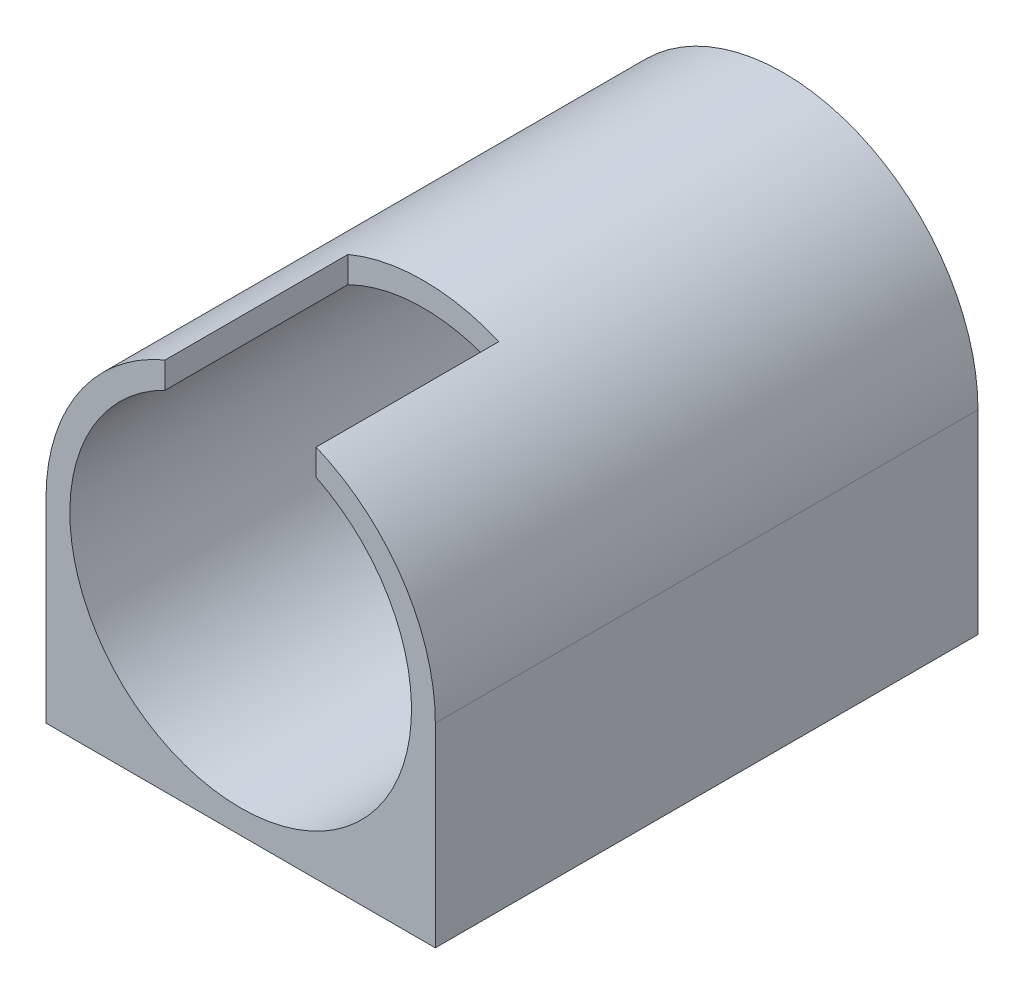
from build123d import *

# Parameters (mm, degrees)
ESQUISSE1_R             = 24.5
ESQUISSE1_R_2           = 21.5
BOSS_EXTRU_1_DEPTH      = 65.3
ESQUISSE2_R             = 21.5
ESQUISSE2_R_2           = 14.5
BOSS_EXTRU_2_DEPTH      = 3
ESQUISSE3_R             = 1.65
ENL_V_MAT_EXTRU_1_DEPTH = 3
ESQUISSE4_W             = 19
ESQUISSE4_H             = 5.738367338
ENL_V_MAT_EXTRU_2_DEPTH = 23
ESQUISSE5_W             = 68.3
ESQUISSE5_H             = 3
BOSS_EXTRU_3_DEPTH      = 17
ESQUISSE6_W             = 68.3
ESQUISSE6_H             = 3
BOSS_EXTRU_4_DEPTH      = 17
ESQUISSE7_R             = 2
ENL_V_MAT_EXTRU_3_DEPTH = 10
ESQUISSE9_R             = 2
ENL_V_MAT_EXTRU_4_DEPTH = 10
ESQUISSE10_R            = 3.5
ENL_V_MAT_EXTRU_5_DEPTH = 1
ESQUISSE11_R            = 2.75
ENL_V_MAT_EXTRU_6_DEPTH = 8
ESQUISSE12_W            = 17
ESQUISSE12_H            = 3
ENL_V_MAT_EXTRU_7_DEPTH = 74


with BuildPart() as part:
    # Esquisse1 → Boss.-Extru.1 (new body)
    with BuildSketch(Plane.XY):
        Circle(ESQUISSE1_R)
        Circle(ESQUISSE1_R_2, mode=Mode.SUBTRACT)
        with BuildLine():
            Line((-24.5, 0), (-24.5, -24.5))
            Line((-24.5, -24.5), (-6e-09, -24.5))
            ThreePointArc((-6e-09, -24.5), (-17.324116141, -17.324116137), (-24.5, 0))
        make_face()
        with BuildLine():
            ThreePointArc((24.5, 0), (17.324116137, -17.324116141), (-6e-09, -24.5))
            Line((-6e-09, -24.5), (24.5, -24.5))
            Line((24.5, -24.5), (24.5, 0))
        make_face()
    extrude(amount=BOSS_EXTRU_1_DEPTH)

    # Esquisse2 → Boss.-Extru.2 (add)
    with BuildSketch(Plane(origin=(0, 0, 0), x_dir=(-1, 0, 0), z_dir=(0, 0, -1))):
        with BuildLine():
            ThreePointArc((24.5, 0), (0, 24.5), (-24.5, 0))
            ThreePointArc((-24.5, 0), (-17.324116141, -17.324116137), (-6e-09, -24.5))
            ThreePointArc((-6e-09, -24.5), (17.324116137, -17.324116141), (24.5, 0))
        make_face()
        with Locations(Location((0, 0, 0), (0, 0, 180))):
            Circle(ESQUISSE2_R, mode=Mode.SUBTRACT)
        with Locations(Location((0, 0, 0), (0, 0, 180))):
            Circle(ESQUISSE2_R)
        Circle(ESQUISSE2_R_2, mode=Mode.SUBTRACT)
        with BuildLine():
            ThreePointArc((-6e-09, -24.5), (-17.324116141, -17.324116137), (-24.5, 0))
            Line((-24.5, 0), (-24.5, -24.5))
            Line((-24.5, -24.5), (-6e-09, -24.5))
        make_face()
        with BuildLine():
            Line((24.5, -24.5), (24.5, 0))
            ThreePointArc((24.5, 0), (17.324116137, -17.324116141), (-6e-09, -24.5))
            Line((-6e-09, -24.5), (24.5, -24.5))
        make_face()
    extrude(amount=BOSS_EXTRU_2_DEPTH)

    # Esquisse3 → Enlèv. mat.-Extru.1 (cut)
    with BuildSketch(Plane(origin=(0, 0, -3), x_dir=(-1, 0, 0), z_dir=(0, 0, -1))):
        with Locations((-17.5, 0)):
            Circle(ESQUISSE3_R)
        with Locations((17.5, 0)):
            Circle(ESQUISSE3_R)
        with Locations((0, 17.5)):
            Circle(ESQUISSE3_R)
        with Locations((0, -17.5)):
            Circle(ESQUISSE3_R)
    extrude(amount=-ENL_V_MAT_EXTRU_1_DEPTH, mode=Mode.SUBTRACT)

    # Esquisse4 → Enlèv. mat.-Extru.2 (cut)
    with BuildSketch(Plane.XY.offset(65.3)):
        with Locations((0, 22.156485191)):
            Rectangle(ESQUISSE4_W, ESQUISSE4_H)
    extrude(amount=-ENL_V_MAT_EXTRU_2_DEPTH, mode=Mode.SUBTRACT)

    # Esquisse5 → Boss.-Extru.3 (add)
    with BuildSketch(Plane.ZY.offset(24.5)):
        with Locations((31.15, -23)):
            Rectangle(ESQUISSE5_W, ESQUISSE5_H)
    extrude(amount=BOSS_EXTRU_3_DEPTH)

    # Esquisse6 → Boss.-Extru.4 (add)
    with BuildSketch(Plane(origin=(24.5, 0, 0), x_dir=(0, 0, -1), z_dir=(1, 0, 0))):
        with Locations((-31.15, -23)):
            Rectangle(ESQUISSE6_W, ESQUISSE6_H)
    extrude(amount=BOSS_EXTRU_4_DEPTH)

    # Esquisse7 → Enlèv. mat.-Extru.3 (cut)
    with BuildSketch(Plane(origin=(0, -21.5, 0), x_dir=(1, 0, 0), z_dir=(0, 1, 0))):
        with Locations(Location((-33, -7, 0), (0, 0, 270))):
            Circle(ESQUISSE7_R)
        with Locations(Location((-33, -55.3, 0), (0, 0, 270))):
            Circle(ESQUISSE7_R)
    extrude(amount=-ENL_V_MAT_EXTRU_3_DEPTH, mode=Mode.SUBTRACT)

    # Esquisse9 → Enlèv. mat.-Extru.4 (cut)
    with BuildSketch(Plane(origin=(0, -21.5, 0), x_dir=(1, 0, 0), z_dir=(0, 1, 0))):
        with Locations(Location((33, -7, 0), (0, 0, 270))):
            Circle(ESQUISSE9_R)
        with Locations(Location((33, -55.3, 0), (0, 0, 270))):
            Circle(ESQUISSE9_R)
    extrude(amount=-ENL_V_MAT_EXTRU_4_DEPTH, mode=Mode.SUBTRACT)

    # Esquisse10 → Enlèv. mat.-Extru.5 (cut)
    with BuildSketch(Plane.XZ.offset(24.5)):
        with Locations(Location((-19.5, 55.3, 0), (0, 0, 270))):
            Circle(ESQUISSE10_R)
        with Locations(Location((19.5, 55.3, 0), (0, 0, 90))):
            Circle(ESQUISSE10_R)
        with Locations(Location((19.5, 7, 0), (0, 0, 270))):
            Circle(ESQUISSE10_R)
        with Locations(Location((-19.5, 7, 0), (0, 0, 90))):
            Circle(ESQUISSE10_R)
    extrude(amount=-ENL_V_MAT_EXTRU_5_DEPTH, mode=Mode.SUBTRACT)

    # Esquisse11 → Enlèv. mat.-Extru.6 (cut)
    with BuildSketch(Plane.XZ.offset(24.5)):
        with Locations(Location((-19.5, 55.3, 0), (0, 0, 270))):
            Circle(ESQUISSE11_R)
        with Locations(Location((19.5, 55.3, 0), (0, 0, 90))):
            Circle(ESQUISSE11_R)
        with Locations(Location((19.5, 7, 0), (0, 0, 270))):
            Circle(ESQUISSE11_R)
        with Locations(Location((-19.5, 7, 0), (0, 0, 90))):
            Circle(ESQUISSE11_R)
    extrude(amount=-ENL_V_MAT_EXTRU_6_DEPTH, mode=Mode.SUBTRACT)

    # Esquisse12 → Enlèv. mat.-Extru.7 (cut)
    with BuildSketch(Plane(origin=(0, 0, -3), x_dir=(-1, 0, 0), z_dir=(0, 0, -1))):
        with Locations((-33, -23)):
            Rectangle(ESQUISSE12_W, ESQUISSE12_H)
        with Locations((33, -23)):
            Rectangle(ESQUISSE12_W, ESQUISSE12_H)
    extrude(amount=-ENL_V_MAT_EXTRU_7_DEPTH, mode=Mode.SUBTRACT)


solid = part.part
